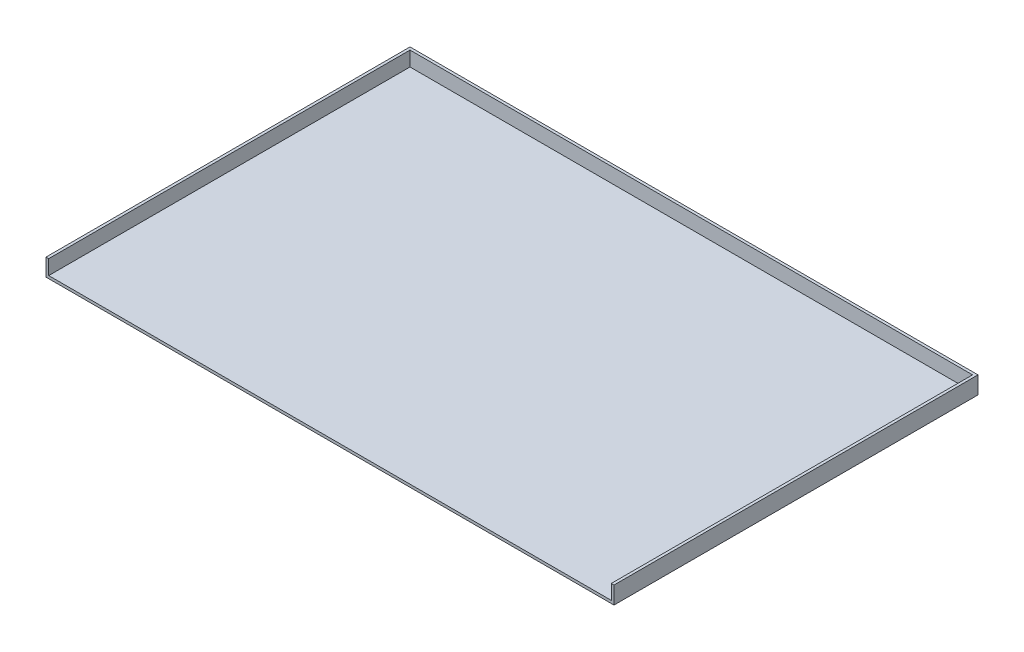
from build123d import *

# Parameters (mm, degrees)
SZKIC1_W                    = 387
SZKIC1_H                    = 1.85
DODANIE_WYCI_GNI_CIE1_DEPTH = 248
DODANIE_WYCI_GNI_CIE2_DEPTH = 10


with BuildPart() as part:
    # Szkic1 → Dodanie-wyciągnięcie1 (new body)
    with BuildSketch(Plane.XY):
        Rectangle(SZKIC1_W, SZKIC1_H)
    extrude(amount=DODANIE_WYCI_GNI_CIE1_DEPTH)

    # Szkic3 → Dodanie-wyciągnięcie2 (add)
    with BuildSketch(Plane(origin=(0, 0.925, 0), x_dir=(1, 0, 0), z_dir=(0, 1, 0))):
        Polygon((193.5, -248), (193.5, 0), (-193.5, 0), (-193.5, -248), (-191.65, -248), (-191.65, -1.85), (191.65, -1.85), (191.65, -248), align=None)
    extrude(amount=DODANIE_WYCI_GNI_CIE2_DEPTH)


solid = part.part
